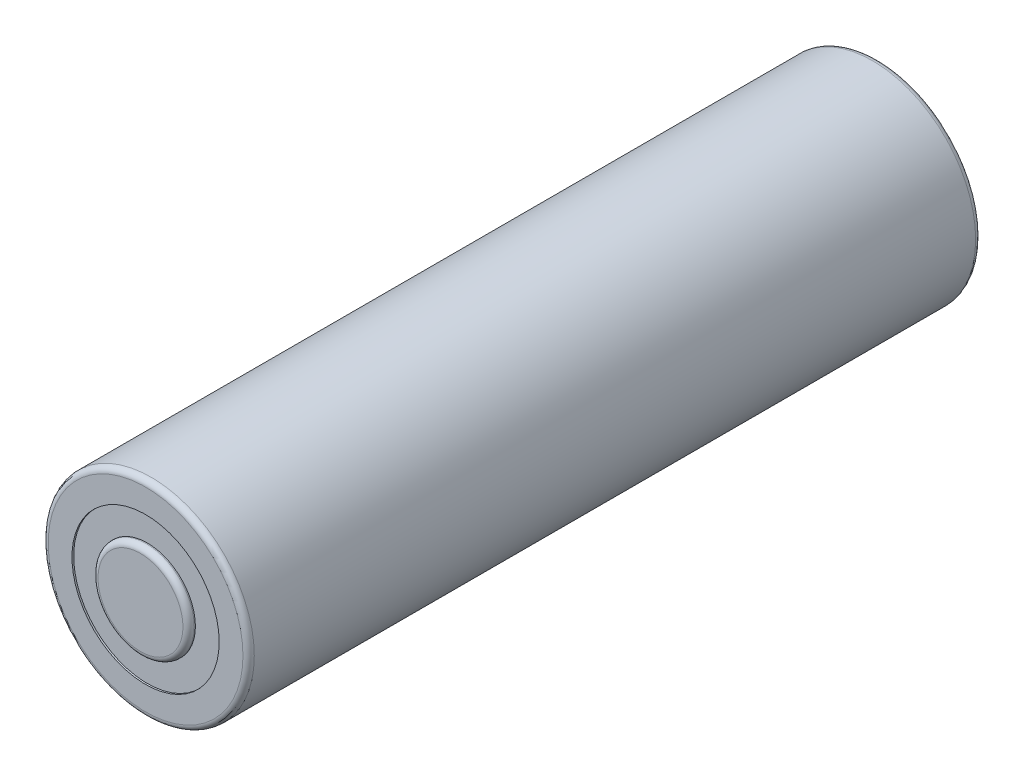
from build123d import *

# Parameters (mm, degrees)
SKETCH_1_R          = 9.1
EXTRUDE_1_DEPTH     = 64.7
FILLET_1_R          = 0.5
FILLET_2_R          = 0.5
SKETCH_2_R          = 6.5
CUT_EXTRUDE_1_DEPTH = 0.35
SKETCH_3_R          = 6.5
CUT_EXTRUDE_2_DEPTH = 0.35
SKETCH_4_R          = 4.25
EXTRUDE_2_DEPTH     = 0.8
FILLET_3_R          = 0.5
SKETCH_5_R          = 6.5
SKETCH_5_R_2        = 4.25
EXTRUDE_3_DEPTH     = 0.2


with BuildPart() as part:
    # 草图1 → 凸台-拉伸1 (new body)
    with BuildSketch(Plane.XY):
        with Locations((-28.874360447, 15.271996124)):
            Circle(SKETCH_1_R)
    extrude(amount=EXTRUDE_1_DEPTH)

    # 圆角1
    fillet_1_edges = [part.edges().sort_by_distance(p)[0] for p in [
        (-37.974360447, 15.271996124, 0),
    ]]
    fillet(fillet_1_edges, radius=FILLET_1_R)

    # 圆角2
    fillet_2_edges = [part.edges().sort_by_distance(p)[0] for p in [
        (-37.974360447, 15.271996124, 64.7),
    ]]
    fillet(fillet_2_edges, radius=FILLET_2_R)

    # 草图2 → 切除-拉伸1 (cut)
    with BuildSketch(Plane(origin=(0, 0, 0), x_dir=(-1, 0, 0), z_dir=(0, 0, -1))):
        with Locations((28.874360447, 15.271996124)):
            Circle(SKETCH_2_R)
    extrude(amount=-CUT_EXTRUDE_1_DEPTH, mode=Mode.SUBTRACT)

    # 草图3 → 切除-拉伸2 (cut)
    with BuildSketch(Plane.XY.offset(64.7)):
        with Locations((-28.874360447, 15.271996124)):
            Circle(SKETCH_3_R)
    extrude(amount=-CUT_EXTRUDE_2_DEPTH, mode=Mode.SUBTRACT)

    # 草图4 → 凸台-拉伸2 (add)
    with BuildSketch(Plane.XY.offset(64.35)):
        with Locations((-28.874360447, 15.271996124)):
            Circle(SKETCH_4_R)
    extrude(amount=EXTRUDE_2_DEPTH)

    # 圆角3
    fillet_3_edges = [part.edges().sort_by_distance(p)[0] for p in [
        (-33.124360447, 15.271996124, 65.15),
    ]]
    fillet(fillet_3_edges, radius=FILLET_3_R)

    # 草图5 → 凸台-拉伸3 (add)
    with BuildSketch(Plane.XY.offset(64.35)):
        with Locations((-28.874360447, 15.271996124)):
            Circle(SKETCH_5_R)
        with Locations((-28.874360447, 15.271996124)):
            Circle(SKETCH_5_R_2, mode=Mode.SUBTRACT)
    extrude(amount=EXTRUDE_3_DEPTH)


solid = part.part
